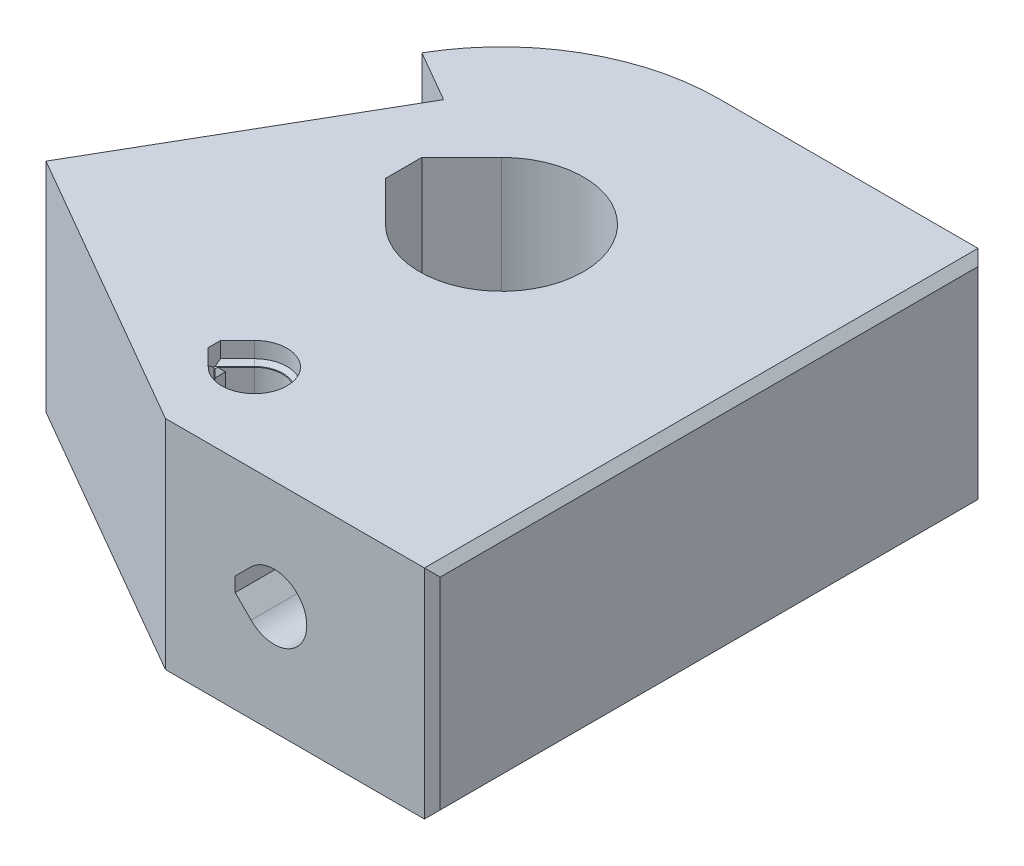
from build123d import *

# Parameters (mm, degrees)
SKETCH1_R           = 4.15
BOSS_EXTRUDE1_DEPTH = 11
SKETCH2_R           = 1.65
CUT_EXTRUDE1_DEPTH  = 29
SKETCH3_R           = 3.7
CUT_EXTRUDE2_DEPTH  = 11
SKETCH5_R           = 1.4
CUT_EXTRUDE4_DEPTH  = 12.0000001
SKETCH11_R          = 1.4
CUT_EXTRUDE10_DEPTH = 14
CUT_EXTRUDE14_DEPTH = 12.0000001
CUT_EXTRUDE15_DEPTH = 11
CUT_EXTRUDE16_DEPTH = 29.0000001
CUT_EXTRUDE21_DEPTH = 12.0000001
SKETCH20_R          = 1.65
CUT_EXTRUDE18_DEPTH = 1
SKETCH21_R          = 1.65
CUT_EXTRUDE19_DEPTH = 1
CUT_EXTRUDE22_DEPTH = 1
CUT_EXTRUDE23_DEPTH = 1
CHAMFER4_SIZE       = 0.4
CUT_EXTRUDE20_DEPTH = 9
CHAMFER5_SIZE       = 0.2


with BuildPart() as part:
    # Sketch1 → Boss-Extrude1 (new body)
    with BuildSketch(Plane(origin=(0, 0, 0), x_dir=(1, 0, 0), z_dir=(0, 1, 0))):
        with BuildLine():
            Line((-7.5, -1), (-21, -1))
            Line((-21, -1), (-35.289419162, 7.25))
            Line((-35.289419162, 7.25), (-31.92820323, 13.07179677))
            Line((-31.92820323, 13.07179677), (-27.92820323, 20))
            Line((-27.92820323, 20), (-30.526279442, 21.5))
            ThreePointArc((-30.526279442, 21.5), (-26.5, 25.526279442), (-21, 27))
            Line((-21, 27), (-7.5, 27))
            Line((-7.5, 27), (-7.5, -1))
        make_face()
        with Locations((-21, 16)):
            Circle(SKETCH1_R, mode=Mode.SUBTRACT)
    extrude(amount=BOSS_EXTRUDE1_DEPTH)

    # Sketch2 → Cut-Extrude1 (cut, through all)
    with BuildSketch(Plane.XY.offset(1)):
        with Locations((-15.5, 5.5)):
            Circle(SKETCH2_R)
    extrude(amount=-CUT_EXTRUDE1_DEPTH, mode=Mode.SUBTRACT)

    # Sketch3 → Cut-Extrude2 (cut)
    with BuildSketch(Plane(origin=(0, 0, -27), x_dir=(-1, 0, 0), z_dir=(0, 0, -1))):
        with Locations((15.5, 5.5)):
            Circle(SKETCH3_R)
    extrude(amount=-CUT_EXTRUDE2_DEPTH, mode=Mode.SUBTRACT)

    # Sketch5 → Cut-Extrude4 (cut, through all)
    with BuildSketch(Plane(origin=(0, 11, 0), x_dir=(1, 0, 0), z_dir=(0, 1, 0))):
        with Locations((-21, 3.5)):
            Circle(SKETCH5_R)
    extrude(amount=-CUT_EXTRUDE4_DEPTH, mode=Mode.SUBTRACT)

    # Sketch11 → Cut-Extrude10 (cut)
    with BuildSketch(Plane(origin=(-29.606406461, 0, -17.09326674), x_dir=(-0.5, 0, 0.866025404), z_dir=(-0.866025404, 0, -0.5))):
        with Locations((3.643593539, 5.5)):
            Circle(SKETCH11_R)
    extrude(amount=-CUT_EXTRUDE10_DEPTH, mode=Mode.SUBTRACT)

    # Sketch16 → Cut-Extrude14 (cut, through all)
    with BuildSketch(Plane.XZ):
        Polygon((-21, -16), (-23.934493142, -18.934493142), (-25.95, -16.918986284), (-25.95, -15.081013716), (-23.934493142, -13.065506858), align=None)
    extrude(amount=-CUT_EXTRUDE14_DEPTH, mode=Mode.SUBTRACT)

    # Sketch17 → Cut-Extrude15 (cut)
    with BuildSketch(Plane(origin=(0, 0, -27), x_dir=(-1, 0, 0), z_dir=(0, 0, -1))):
        Polygon((15.5, 5.5), (18.11629509, 2.88370491), (19.94, 4.707409819), (19.94, 6.292590181), (18.11629509, 8.11629509), align=None)
    extrude(amount=-CUT_EXTRUDE15_DEPTH, mode=Mode.SUBTRACT)

    # Sketch18 → Cut-Extrude16 (cut, through all)
    with BuildSketch(Plane.XY.offset(1)):
        Polygon((-15.5, 5.5), (-16.666726189, 6.666726189), (-17.47, 5.863452378), (-17.47, 5.136547622), (-16.666726189, 4.333273811), align=None)
    extrude(amount=-CUT_EXTRUDE16_DEPTH, mode=Mode.SUBTRACT)

    # Sketch23 → Cut-Extrude21 (cut, through all)
    with BuildSketch(Plane.XZ):
        Polygon((-21.989949494, -2.510050506), (-22.72, -3.240101013), (-22.72, -3.759898987), (-21.989949494, -4.489949494), align=None)
    extrude(amount=-CUT_EXTRUDE21_DEPTH, mode=Mode.SUBTRACT)

    # Sketch20 → Cut-Extrude18 (cut)
    with BuildSketch(Plane(origin=(0, 11, 0), x_dir=(1, 0, 0), z_dir=(0, 1, 0))):
        with Locations((-21, 3.5)):
            Circle(SKETCH20_R)
    extrude(amount=-CUT_EXTRUDE18_DEPTH, mode=Mode.SUBTRACT)

    # Sketch21 → Cut-Extrude19 (cut)
    with BuildSketch(Plane.XZ):
        with Locations((-21, -3.5)):
            Circle(SKETCH21_R)
    extrude(amount=-CUT_EXTRUDE19_DEPTH, mode=Mode.SUBTRACT)

    # Sketch24 → Cut-Extrude22 (cut)
    with BuildSketch(Plane.XZ):
        Polygon((-22.166726189, -2.333273811), (-23.02, -3.186547622), (-23.02, -3.813452378), (-22.166726189, -4.666726189), align=None)
    extrude(amount=-CUT_EXTRUDE22_DEPTH, mode=Mode.SUBTRACT)

    # Sketch25 → Cut-Extrude23 (cut)
    with BuildSketch(Plane(origin=(0, 11, 0), x_dir=(1, 0, 0), z_dir=(0, 1, 0))):
        Polygon((-23.02, 3.186547622), (-23.02, 3.813452378), (-22.166726189, 4.666726189), (-22.166726189, 2.333273811), align=None)
    extrude(amount=-CUT_EXTRUDE23_DEPTH, mode=Mode.SUBTRACT)

    # Chamfer4
    chamfer4_edges = [part.edges().sort_by_distance(p)[0] for p in [
        (-7.5, 11, -13),
        (-7.5, 5.5, -27),
        (-7.5, 5.5, 1),
        (-7.5, 0, -13),
    ]]
    chamfer(chamfer4_edges, length=CHAMFER4_SIZE)

    # Sketch22 → Cut-Extrude20 (cut)
    with BuildSketch(Plane(origin=(-29.606406461, 0, -17.09326674), x_dir=(-0.5, 0, 0.866025404), z_dir=(-0.866025404, 0, -0.5))):
        with BuildLine():
            ThreePointArc((2.441512011, 6.702081528), (3.643593539, 3.8), (4.845675067, 6.702081528))
            ThreePointArc((4.845675067, 6.702081528), (3.643593539, 7.2), (2.441512011, 6.702081528))
        make_face()
    extrude(amount=-CUT_EXTRUDE20_DEPTH, mode=Mode.SUBTRACT)

    # Chamfer5
    chamfer5_edges = [part.edges().sort_by_distance(p)[0] for p in [
        (-22.354974747, 1, -2.87507576),
        (-19.6, 1, -3.5),
        (-22.354974747, 1, -4.12492424),
        (-22.72, 1, -3.5),
        (-19.35, 10, -3.5),
        (-22.593363094, 10, -2.759910717),
        (-22.593363094, 10, -4.240089283),
        (-22.72, 10, -3.5),
    ]]
    chamfer(chamfer5_edges, length=CHAMFER5_SIZE)


solid = part.part
